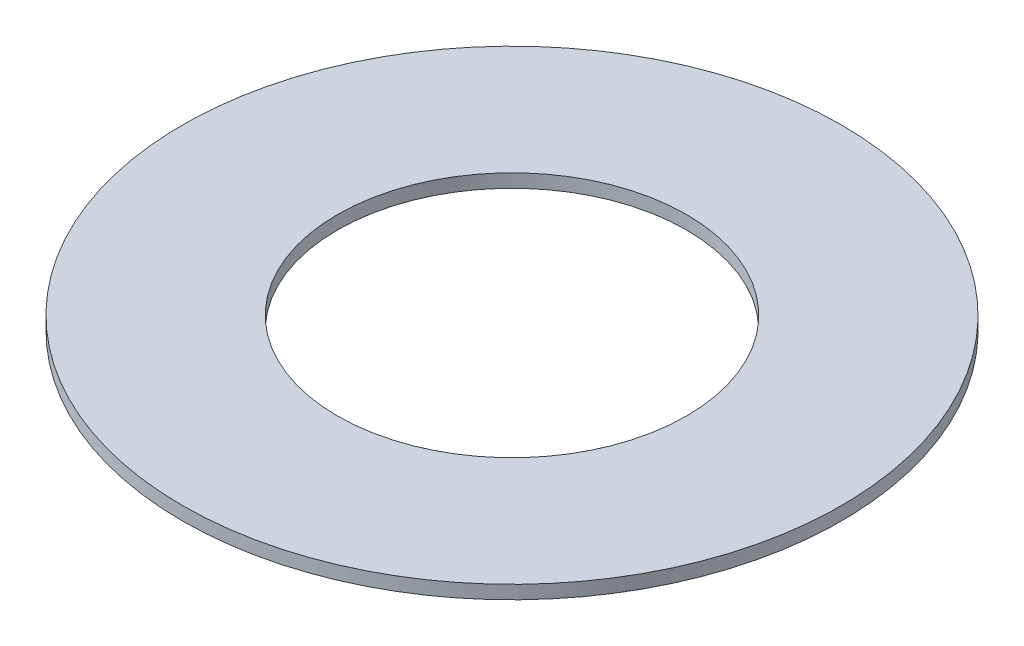
from build123d import *

# Parameters (mm, degrees)
SKETCH1_R           = 4.91
SKETCH1_R_2         = 2.6
BOSS_EXTRUDE1_DEPTH = 0.2


with BuildPart() as part:
    # Sketch1 → Boss-Extrude1 (new body)
    with BuildSketch(Plane(origin=(0, 0, 0), x_dir=(1, 0, 0), z_dir=(0, 1, 0))):
        Circle(SKETCH1_R)
        Circle(SKETCH1_R_2, mode=Mode.SUBTRACT)
    extrude(amount=BOSS_EXTRUDE1_DEPTH)


solid = part.part
